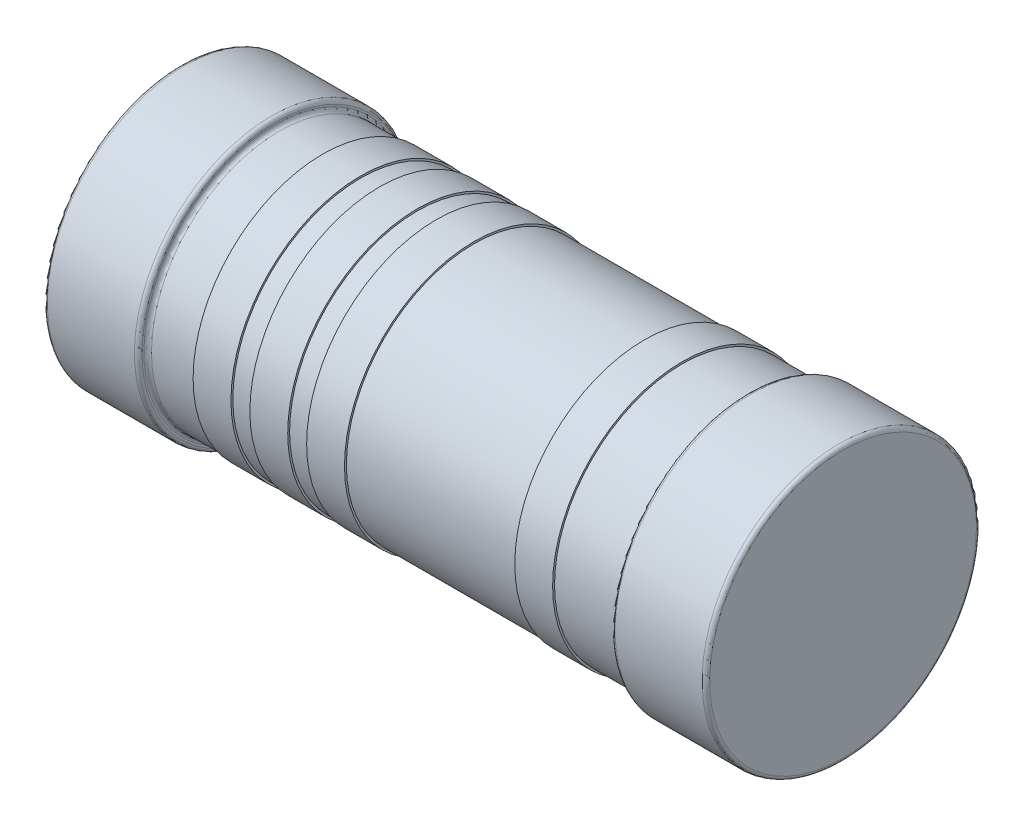
from build123d import *


with BuildPart() as part:
    # Sketch1 → Revolve1 (revolve)
    with BuildSketch(Plane.XY):
        with BuildLine():
            Line((-1.75, 0.725), (1.75, 0.725))
            Line((1.75, 0.725), (1.75, 0.02))
            ThreePointArc((1.75, 0.02), (1.744142136, 0.005857864), (1.73, 0))
            Line((1.73, 0), (1.27, 0))
            ThreePointArc((1.27, 0), (1.255857864, 0.005857864), (1.25, 0.02))
            Line((1.25, 0.02), (1.25, 0.03))
            ThreePointArc((1.25, 0.03), (1.244142136, 0.044142136), (1.23, 0.05))
            Line((1.23, 0.05), (0.9, 0.05))
            Line((0.9, 0.05), (0.9, 0.04))
            Line((0.9, 0.04), (0.7, 0.04))
            Line((0.7, 0.04), (0.7, 0.05))
            Line((0.7, 0.05), (-0.2, 0.05))
            Line((-0.2, 0.05), (-0.2, 0.04))
            Line((-0.2, 0.04), (-0.4, 0.04))
            Line((-0.4, 0.04), (-0.4, 0.05))
            Line((-0.4, 0.05), (-0.5, 0.05))
            Line((-0.5, 0.05), (-0.5, 0.04))
            Line((-0.5, 0.04), (-0.7, 0.04))
            Line((-0.7, 0.04), (-0.7, 0.05))
            Line((-0.7, 0.05), (-0.8, 0.05))
            Line((-0.8, 0.05), (-0.8, 0.04))
            Line((-0.8, 0.04), (-1, 0.04))
            Line((-1, 0.04), (-1, 0.05))
            Line((-1, 0.05), (-1.23, 0.05))
            ThreePointArc((-1.23, 0.05), (-1.244142136, 0.044142136), (-1.25, 0.03))
            Line((-1.25, 0.03), (-1.25, 0.02))
            ThreePointArc((-1.25, 0.02), (-1.255857864, 0.005857864), (-1.27, 0))
            Line((-1.27, 0), (-1.73, 0))
            ThreePointArc((-1.73, 0), (-1.744142136, 0.005857864), (-1.75, 0.02))
            Line((-1.75, 0.02), (-1.75, 0.725))
        make_face()
    revolve(axis=Axis((-1.75, 0.725, 0), (-1, 0, 0)))


solid = part.part
